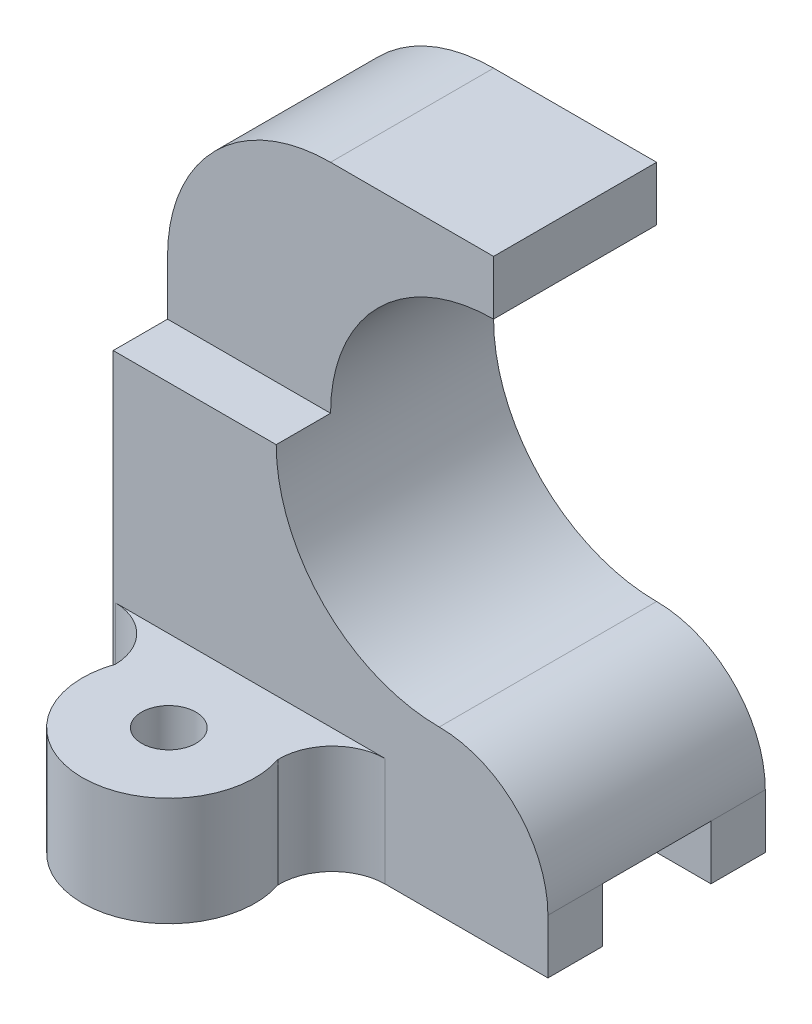
from build123d import *

# Parameters (mm, degrees)
SKETCH1_W           = 80
SKETCH1_H           = 40
BOSS_EXTRUDE1_DEPTH = 100
CUT_EXTRUDE1_DEPTH  = 100
SKETCH4_W           = 20
SKETCH4_H           = 10
CUT_EXTRUDE2_DEPTH  = 100
SKETCH5_W           = 10
SKETCH5_H           = 40
CUT_EXTRUDE3_DEPTH  = 100
SKETCH7_R           = 5
BOSS_EXTRUDE2_DEPTH = 20


with BuildPart() as part:
    # Sketch1 → Boss-Extrude1 (new body)
    with BuildSketch(Plane(origin=(0, 0, 0), x_dir=(1, 0, 0), z_dir=(0, 1, 0))):
        Rectangle(SKETCH1_W, SKETCH1_H)
    extrude(amount=BOSS_EXTRUDE1_DEPTH)

    # Sketch2 → Cut-Extrude1 (cut)
    with BuildSketch(Plane.XY.offset(20)):
        with BuildLine():
            ThreePointArc((20, 30), (34.142135624, 24.142135624), (40, 10))
            Line((40, 10), (40, 100))
            Line((40, 100), (20, 100))
            Line((20, 100), (20, 90))
            ThreePointArc((20, 90), (-10, 60), (20, 30))
        make_face()
        with BuildLine():
            Line((-40, 100), (-40, 70))
            ThreePointArc((-40, 70), (-31.213203436, 91.213203436), (-10, 100))
            Line((-10, 100), (-40, 100))
        make_face()
    extrude(amount=-CUT_EXTRUDE1_DEPTH, mode=Mode.SUBTRACT)

    # Sketch4 → Cut-Extrude2 (cut)
    with BuildSketch(Plane(origin=(40, 0, 0), x_dir=(0, 0, -1), z_dir=(1, 0, 0))):
        with Locations((0, 5)):
            Rectangle(SKETCH4_W, SKETCH4_H)
    extrude(amount=-CUT_EXTRUDE2_DEPTH, mode=Mode.SUBTRACT)

    # Sketch5 → Cut-Extrude3 (cut)
    with BuildSketch(Plane(origin=(20, 0, 0), x_dir=(0, 0, -1), z_dir=(1, 0, 0))):
        with Locations((-15, 80)):
            Rectangle(SKETCH5_W, SKETCH5_H)
    extrude(amount=-CUT_EXTRUDE3_DEPTH, mode=Mode.SUBTRACT)

    # Sketch7 → Boss-Extrude2 (add)
    with BuildSketch(Plane(origin=(0, 0, 0), x_dir=(1, 0, 0), z_dir=(0, 1, 0))):
        with BuildLine():
            Line((10, -20), (-39.600122702, -20))
            ThreePointArc((-39.600122702, -20), (-32.728993539, -22.926933215), (-29.802060324, -29.798062378))
            ThreePointArc((-29.802060324, -29.798062378), (-14.874330774, -50.906091293), (0.33492105, -30))
            ThreePointArc((0.33492105, -30), (3.085632278, -22.987896563), (10, -20))
        make_face()
        with Locations((-14.767737438, -34.998201696)):
            Circle(SKETCH7_R, mode=Mode.SUBTRACT)
    extrude(amount=BOSS_EXTRUDE2_DEPTH)


solid = part.part
